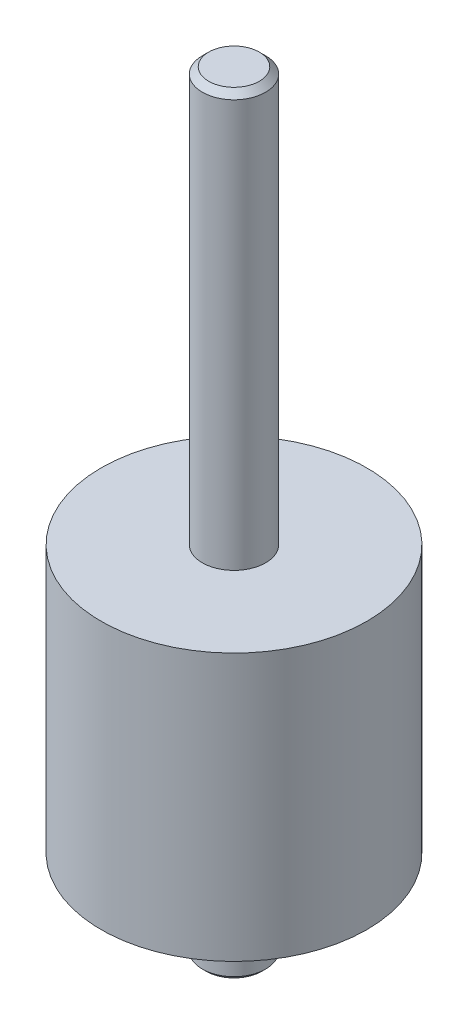
from build123d import *

# Parameters (mm, degrees)
CHAMFER1_SIZE = 0.3
CHAMFER2_SIZE = 0.5


with BuildPart() as part:
    # Sketch1 → Revolve1 (revolve)
    with BuildSketch(Plane.XY):
        Polygon((0, -38.6), (2.5, -38.6), (2.5, -31.6), (10.5, -31.6), (10.5, -10.5), (2.5, -10.5), (2.5, 22.2), (0, 22.2), align=None)
    revolve(axis=Axis((0, 22.2, 0), (0, -1, 0)))

    # Chamfer1
    chamfer1_edges = [part.edges().sort_by_distance(p)[0] for p in [
        (-2.5, -38.6, 0),
    ]]
    chamfer(chamfer1_edges, length=CHAMFER1_SIZE)

    # Chamfer2
    chamfer2_edges = [part.edges().sort_by_distance(p)[0] for p in [
        (-2.5, 22.2, 0),
    ]]
    chamfer(chamfer2_edges, length=CHAMFER2_SIZE)


solid = part.part
